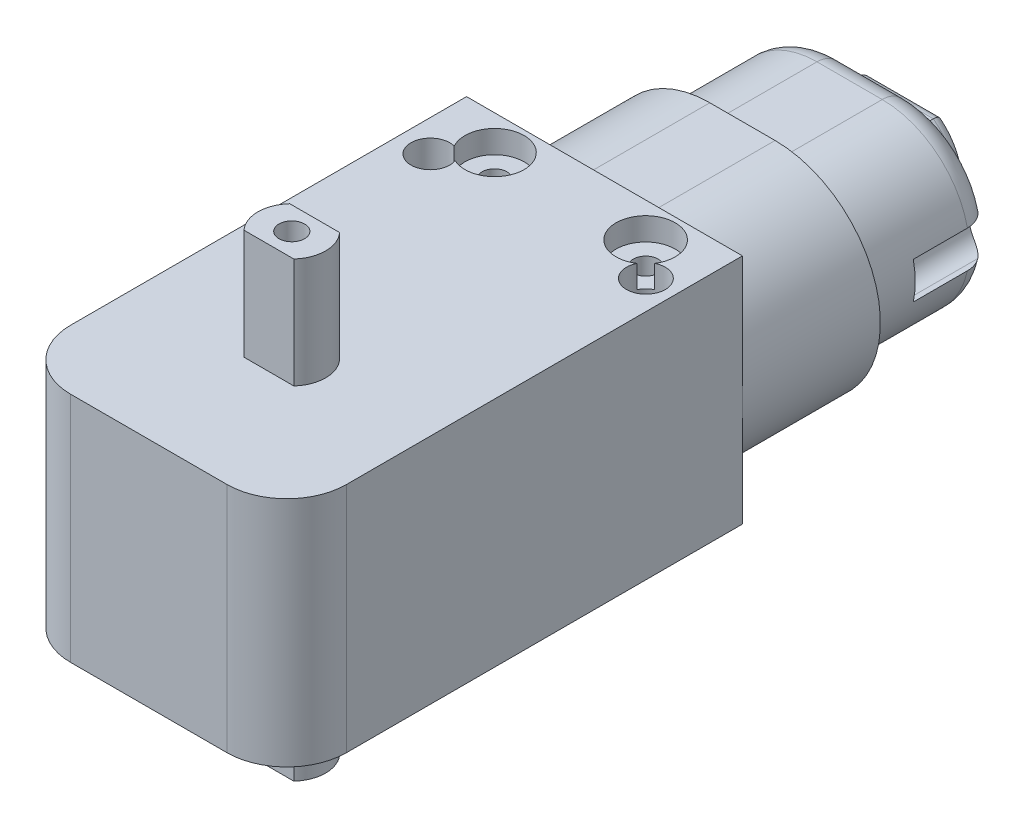
from build123d import *

# Parameters (mm, degrees)
SKETCH2_W           = 37
SKETCH2_H           = 18.86
BOSS_EXTRUDE1_DEPTH = 11.2
FILLET1_R           = 4.85
BOSS_EXTRUDE2_DEPTH = 11.2
BOSS_EXTRUDE3_DEPTH = 13.3
CUT_EXTRUDE1_DEPTH  = 2.5
FILLET2_R           = 0.8
FILLET3_R           = 2.1
CUT_EXTRUDE2_DEPTH  = 6.5
BOSS_EXTRUDE5_DEPTH = 8.93
SKETCH11_R          = 1.04
CUT_EXTRUDE4_DEPTH  = 8.93
CUT_EXTRUDE5_REACH  = 29.79
SKETCH12_R          = 1.575
SKETCH13_R          = 2.4
CUT_EXTRUDE6_DEPTH  = 1.85
SKETCH14_R          = 1
CUT_EXTRUDE7_DEPTH  = 10


with BuildPart() as part:
    # Sketch2 → Boss-Extrude1 (new body, symmetric)
    with BuildSketch(Plane(origin=(0, 0, 0), x_dir=(0, 0, -1), z_dir=(1, 0, 0))):
        Rectangle(SKETCH2_W, SKETCH2_H)
    extrude(amount=BOSS_EXTRUDE1_DEPTH, both=True)

    # Fillet1
    fillet1_edges = [part.edges().sort_by_distance(p)[0] for p in [
        (11.2, 0, 18.5),
        (-11.2, 0, 18.5),
    ]]
    fillet(fillet1_edges, radius=FILLET1_R)

    # Sketch3 → Boss-Extrude2 (add)
    with BuildSketch(Plane(origin=(0, 0, -18.5), x_dir=(-1, 0, 0), z_dir=(0, 0, -1))):
        with BuildLine():
            Line((-2.65, 7.67), (2.65, 7.67))
            ThreePointArc((2.65, 7.67), (11.2, -0.88), (2.65, -9.43))
            Line((2.65, -9.43), (-2.65, -9.43))
            ThreePointArc((-2.65, -9.43), (-11.2, -0.88), (-2.65, 7.67))
        make_face()
    extrude(amount=BOSS_EXTRUDE2_DEPTH)

    # Sketch4 → Boss-Extrude3 (add)
    with BuildSketch(Plane(origin=(0, 0, -29.7), x_dir=(-1, 0, 0), z_dir=(0, 0, -1))):
        with BuildLine():
            Line((-2.65, -7.96), (2.65, -7.96))
            ThreePointArc((2.65, -7.96), (9.73, -0.88), (2.65, 6.2))
            Line((2.65, 6.2), (-2.65, 6.2))
            ThreePointArc((-2.65, 6.2), (-9.73, -0.88), (-2.65, -7.96))
        make_face()
    extrude(amount=BOSS_EXTRUDE3_DEPTH)

    # Sketch5 → Cut-Extrude1 (cut)
    with BuildSketch(Plane(origin=(0, 0, -43), x_dir=(-1, 0, 0), z_dir=(0, 0, -1))):
        with BuildLine():
            Line((-2.65, -7.96), (2.65, -7.96))
            ThreePointArc((2.65, -7.96), (9.73, -0.88), (2.65, 6.2))
            Line((2.65, 6.2), (-2.65, 6.2))
            ThreePointArc((-2.65, 6.2), (-9.73, -0.88), (-2.65, -7.96))
        make_face()
        with BuildLine():
            Line((-3, 3.12), (3, 3.12))
            ThreePointArc((3, 3.12), (0, -5.88), (-3, 3.12))
        make_face(mode=Mode.SUBTRACT)
    extrude(amount=-CUT_EXTRUDE1_DEPTH, mode=Mode.SUBTRACT)

    # Fillet2
    fillet2_edges = [part.edges().sort_by_distance(p)[0] for p in [
        (0, -5.88, -43),
        (0, 3.12, -43),
    ]]
    fillet(fillet2_edges, radius=FILLET2_R)

    # Fillet3
    fillet3_edges = [part.edges().sort_by_distance(p)[0] for p in [
        (9.73, -0.88, -40.5),
        (0, 6.2, -40.5),
        (-9.73, -0.88, -40.5),
        (0, -7.96, -40.5),
    ]]
    fillet(fillet3_edges, radius=FILLET3_R)

    # Sketch6 → Cut-Extrude2 (cut)
    with BuildSketch(Plane(origin=(0, 0, -40.5), x_dir=(-1, 0, 0), z_dir=(0, 0, -1))):
        with BuildLine():
            Line((9.13, 0.62), (11.2, 0.62))
            ThreePointArc((11.2, 0.62), (12.7, -0.88), (11.2, -2.38))
            Line((11.2, -2.38), (9.13, -2.38))
            ThreePointArc((9.13, -2.38), (7.63, -0.88), (9.13, 0.62))
        make_face()
    cut_extrude2 = extrude(amount=-CUT_EXTRUDE2_DEPTH, mode=Mode.SUBTRACT)

    # Mirror1: Cut-Extrude2 across plane
    add(cut_extrude2.mirror(Plane(origin=(0, 0, 0), x_dir=(0, 0, 1), z_dir=(1, 0, 0))), mode=Mode.SUBTRACT)

    # Sketch10 → Boss-Extrude5 (add)
    with BuildSketch(Plane(origin=(0, 9.43, 0), x_dir=(1, 0, 0), z_dir=(0, 1, 0))):
        with BuildLine():
            Line((-1.915561651, -8.86), (2.135561651, -8.86))
            ThreePointArc((2.135561651, -8.86), (2.86, -7), (2.135561651, -5.14))
            Line((2.135561651, -5.14), (-1.915561651, -5.14))
            ThreePointArc((-1.915561651, -5.14), (-2.64, -7), (-1.915561651, -8.86))
        make_face()
    boss_extrude5 = extrude(amount=BOSS_EXTRUDE5_DEPTH)

    # Sketch11 → Cut-Extrude4 (cut)
    with BuildSketch(Plane(origin=(0, 18.36, 0), x_dir=(1, 0, 0), z_dir=(0, 1, 0))):
        with Locations((0.11, -7)):
            Circle(SKETCH11_R)
    cut_extrude4 = extrude(amount=-CUT_EXTRUDE4_DEPTH, mode=Mode.SUBTRACT)

    # Mirror3: Boss-Extrude5, Cut-Extrude4 across plane
    add(boss_extrude5.mirror(Plane.ZX))
    add(cut_extrude4.mirror(Plane.ZX), mode=Mode.SUBTRACT)

    # Sketch12 → Cut-Extrude5 (cut, up to next)
    with BuildSketch(Plane.XZ.offset(9.43), mode=Mode.PRIVATE) as cut_extrude5_sk1:
        with Locations((8.861437687, -13)):
            Circle(SKETCH12_R)
    cut_extrude5_tool1 = extrude(cut_extrude5_sk1.sketch, amount=-CUT_EXTRUDE5_REACH, mode=Mode.PRIVATE) & part.part
    add(cut_extrude5_tool1.solids().sort_by_distance((8.861438, -9.43, -13))[0], mode=Mode.SUBTRACT)
    # Sketch12 → Cut-Extrude5 (cut, up to next)
    with BuildSketch(Plane.XZ.offset(9.43), mode=Mode.PRIVATE) as cut_extrude5_sk2:
        with Locations((-8.638562313, -13)):
            Circle(SKETCH12_R)
    cut_extrude5_tool2 = extrude(cut_extrude5_sk2.sketch, amount=-CUT_EXTRUDE5_REACH, mode=Mode.PRIVATE) & part.part
    add(cut_extrude5_tool2.solids().sort_by_distance((-8.638562, -9.43, -13))[0], mode=Mode.SUBTRACT)

    # Sketch13 → Cut-Extrude6 (cut)
    with BuildSketch(Plane(origin=(0, 9.43, 0), x_dir=(1, 0, 0), z_dir=(0, 1, 0))):
        with Locations((6.14, 15.7)):
            Circle(SKETCH13_R)
        with Locations((-6.13, 15.7)):
            Circle(SKETCH13_R)
    extrude(amount=-CUT_EXTRUDE6_DEPTH, mode=Mode.SUBTRACT)

    # Sketch14 → Cut-Extrude7 (cut)
    with BuildSketch(Plane(origin=(0, 7.58, 0), x_dir=(1, 0, 0), z_dir=(0, 1, 0))):
        with Locations((-6.13, 15.7)):
            Circle(SKETCH14_R)
        with Locations((6.14, 15.7)):
            Circle(SKETCH14_R)
    extrude(amount=-CUT_EXTRUDE7_DEPTH, mode=Mode.SUBTRACT)


solid = part.part
